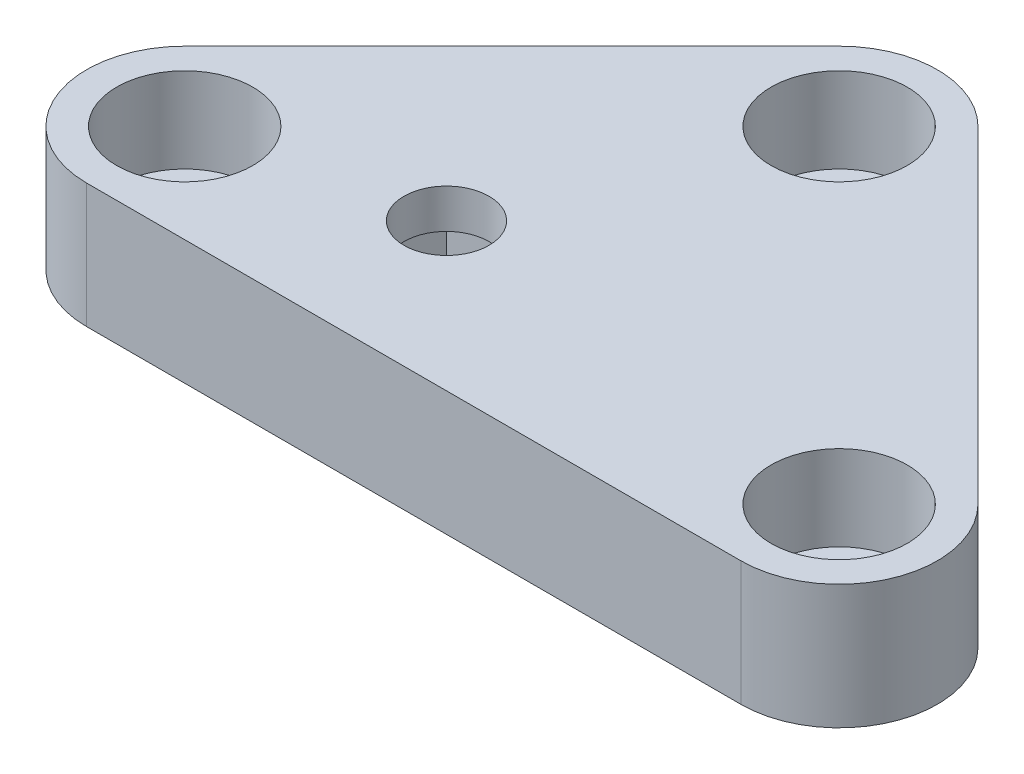
from build123d import *

# Parameters (mm, degrees)
SKETCH_1_R          = 3.25
SKETCH_1_R_2        = 3.2
EXTRUDE_1_DEPTH     = 9.5
SKETCH_2_R          = 5.2
CUT_EXTRUDE_1_DEPTH = 6.5
SKETCH_3_W          = 10.4
SKETCH_3_H          = 10.4
SKETCH_3_R          = 3.25
CUT_EXTRUDE_2_DEPTH = 6.5


with BuildPart() as part:
    # 스케치1 → 보스-돌출1 (new body)
    with BuildSketch(Plane(origin=(0, 0, 0), x_dir=(1, 0, 0), z_dir=(0, 1, 0))):
        with BuildLine():
            Line((3.446699141, -53.446699141), (-21.553300859, -78.446699141))
            ThreePointArc((-21.553300859, -78.446699141), (-23.179096494, -86.620125743), (-16.25, -91.25))
            Line((-16.25, -91.25), (33.75, -91.25))
            ThreePointArc((33.75, -91.25), (40.679096494, -86.620125743), (39.053300859, -78.446699141))
            Line((39.053300859, -78.446699141), (14.053300859, -53.446699141))
            ThreePointArc((14.053300859, -53.446699141), (8.75, -51.25), (3.446699141, -53.446699141))
        make_face()
        with Locations((0, -80)):
            Circle(SKETCH_1_R, mode=Mode.SUBTRACT)
        with Locations((-16.25, -83.75)):
            Circle(SKETCH_1_R_2, mode=Mode.SUBTRACT)
        with Locations((8.75, -58.75)):
            Circle(SKETCH_1_R_2, mode=Mode.SUBTRACT)
        with Locations((33.75, -83.75)):
            Circle(SKETCH_1_R_2, mode=Mode.SUBTRACT)
    extrude(amount=EXTRUDE_1_DEPTH)

    # 스케치2 → 컷-돌출1 (cut)
    with BuildSketch(Plane(origin=(0, 9.5, 0), x_dir=(1, 0, 0), z_dir=(0, 1, 0))):
        with Locations((8.75, -58.75)):
            Circle(SKETCH_2_R)
        with Locations((33.75, -83.75)):
            Circle(SKETCH_2_R)
        with Locations((-16.25, -83.75)):
            Circle(SKETCH_2_R)
    extrude(amount=-CUT_EXTRUDE_1_DEPTH, mode=Mode.SUBTRACT)

    # 스케치3 → 컷-돌출2 (cut)
    with BuildSketch(Plane.XZ):
        with Locations((0, 80)):
            Rectangle(SKETCH_3_W, SKETCH_3_H)
        with Locations((0, 80)):
            Circle(SKETCH_3_R, mode=Mode.SUBTRACT)
    extrude(amount=-CUT_EXTRUDE_2_DEPTH, mode=Mode.SUBTRACT)


solid = part.part
